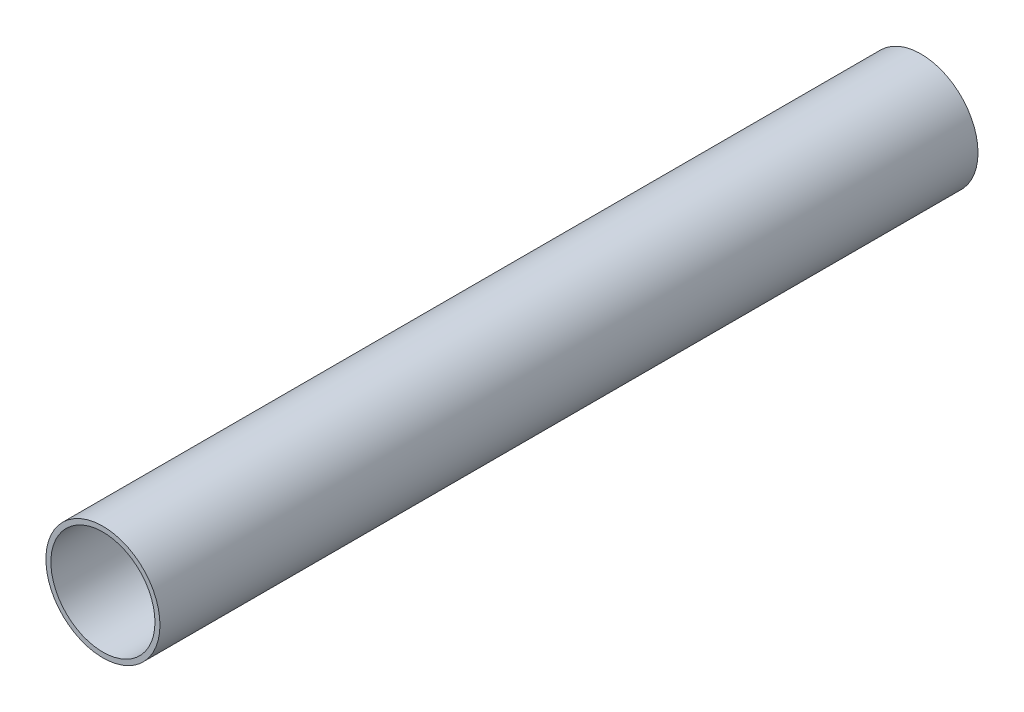
from build123d import *

# Parameters (mm, degrees)
SKETCH1_R           = 15.9385
SKETCH1_R_2         = 14.5415
BOSS_EXTRUDE1_DEPTH = 228.6


with BuildPart() as part:
    # Sketch1 → Boss-Extrude1 (new body)
    with BuildSketch(Plane.XY):
        Circle(SKETCH1_R)
        Circle(SKETCH1_R_2, mode=Mode.SUBTRACT)
    extrude(amount=BOSS_EXTRUDE1_DEPTH)


solid = part.part
